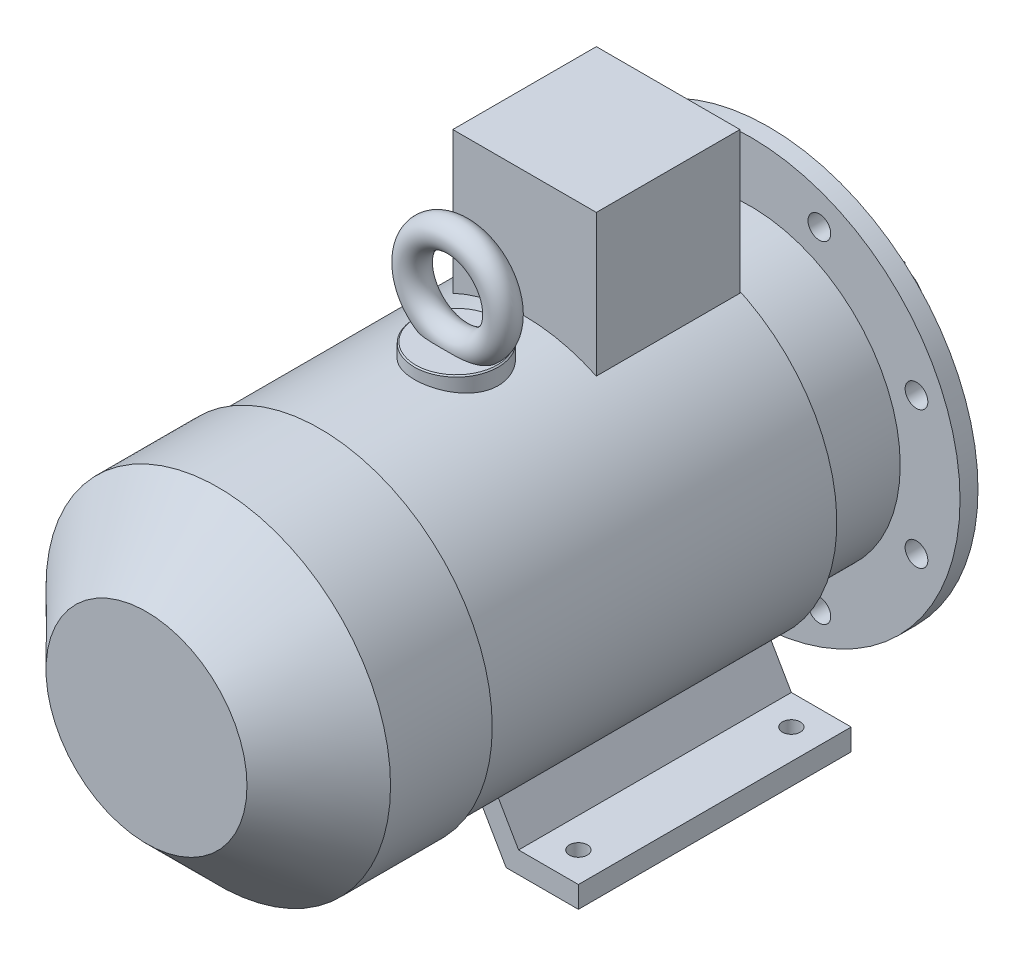
from build123d import *

# Parameters (mm, degrees)
SKETCH_1_R           = 21
EXTRUDE_1_DEPTH      = 110
SKETCH_2_W           = 8
SKETCH_2_H           = 8
EXTRUDE_2_DEPTH      = 0.1
EXTRUDE_2_DEPTH_BACK = 55
SKETCH_3_R           = 175
EXTRUDE_3_DEPTH      = 15
SKETCH_4_R           = 125
SKETCH_4_R_2         = 116
EXTRUDE_4_DEPTH      = 5
SKETCH_5_R           = 116
SKETCH_5_R_2         = 40
CUT_EXTRUDE_1_DEPTH  = 8
CHAMFER_1_SIZE       = 1
SKETCH_6_R           = 9.5
CUT_EXTRUDE_2_DEPTH  = 16
SKETCH_7_R           = 125
EXTRUDE_5_DEPTH      = 68
SKETCH_8_R           = 140
EXTRUDE_6_DEPTH      = 292
SKETCH_9_R           = 144
EXTRUDE_7_DEPTH      = 145
CHAMFER_2_SIZE       = 60
EXTRUDE_8_DEPTH      = 228
CUT_EXTRUDE_3_REACH  = 337
SKETCH_11_R          = 7.5
SKETCH_12_W          = 120
SKETCH_12_H          = 120
EXTRUDE_9_DEPTH      = 245
SKETCH_13_R          = 35
EXTRUDE_10_DEPTH     = 150
CHAMFER_3_SIZE       = 1
SKETCH_15_R          = 12
SKETCH_16_R          = 16
EXTRUDE_11_DEPTH     = 14
EXTRUDE_12_DEPTH     = 16
SKETCH_18_R          = 7
CUT_EXTRUDE_4_DEPTH  = 16


with BuildPart() as part:
    # Эскиз1 → Вытянуть1 (new body)
    with BuildSketch(Plane.XY):
        Circle(SKETCH_1_R)
    extrude(amount=EXTRUDE_1_DEPTH)

    # Эскиз2 → Вытянуть2 (add, two sides)
    with BuildSketch(Plane(origin=(0, 0, 0), x_dir=(-1, 0, 0), z_dir=(0, 0, -1))) as extrude_2_sk:
        with Locations((0, 20)):
            Rectangle(SKETCH_2_W, SKETCH_2_H)
    extrude(amount=EXTRUDE_2_DEPTH)
    extrude(extrude_2_sk.sketch, amount=-EXTRUDE_2_DEPTH_BACK)

    # Эскиз3 → Вытянуть3 (add)
    with BuildSketch(Plane.XY.offset(110)):
        Circle(SKETCH_3_R)
    extrude(amount=EXTRUDE_3_DEPTH)

    # Эскиз4 → Вытянуть4 (add)
    with BuildSketch(Plane(origin=(0, 0, 110), x_dir=(-1, 0, 0), z_dir=(0, 0, -1))):
        with Locations(Location((0, 0, 0), (0, 0, 180))):  # turned: the seam where the file's is
            Circle(SKETCH_4_R)
        Circle(SKETCH_4_R_2, mode=Mode.SUBTRACT)
    extrude(amount=EXTRUDE_4_DEPTH)

    # Эскиз5 → Вырез-Вытянуть1 (cut)
    with BuildSketch(Plane(origin=(0, 0, 110), x_dir=(-1, 0, 0), z_dir=(0, 0, -1))):
        Circle(SKETCH_5_R)
        Circle(SKETCH_5_R_2, mode=Mode.SUBTRACT)
    extrude(amount=-CUT_EXTRUDE_1_DEPTH, mode=Mode.SUBTRACT)

    # Фаска1
    chamfer_1_edges = [part.edges().sort_by_distance(p)[0] for p in [
        (-125, 0, 105),
        (40, 0, 110),
        (-13.360389216, -16.201851746, 0),
    ]]
    chamfer(chamfer_1_edges, length=CHAMFER_1_SIZE)

    # Эскиз6 → Вырез-Вытянуть2 (cut, through all)
    with BuildSketch(Plane(origin=(0, 0, 110), x_dir=(-1, 0, 0), z_dir=(0, 0, -1))):
        with Locations((-57.402514855, 138.581929877)):
            Circle(SKETCH_6_R)
        with Locations((57.402514855, 138.581929877)):
            Circle(SKETCH_6_R)
        with Locations((138.581929877, 57.402514855)):
            Circle(SKETCH_6_R)
        with Locations((138.581929877, -57.402514855)):
            Circle(SKETCH_6_R)
        with Locations((57.402514855, -138.581929877)):
            Circle(SKETCH_6_R)
        with Locations((-57.402514855, -138.581929877)):
            Circle(SKETCH_6_R)
        with Locations((-138.581929877, -57.402514855)):
            Circle(SKETCH_6_R)
        with Locations((-138.581929877, 57.402514855)):
            Circle(SKETCH_6_R)
    extrude(amount=-CUT_EXTRUDE_2_DEPTH, mode=Mode.SUBTRACT)

    # Эскиз7 → Вытянуть5 (add)
    with BuildSketch(Plane.XY.offset(125)):
        Circle(SKETCH_7_R)
    extrude(amount=EXTRUDE_5_DEPTH)

    # Эскиз8 → Вытянуть6 (add)
    with BuildSketch(Plane.XY.offset(193)):
        Circle(SKETCH_8_R)
    extrude(amount=EXTRUDE_6_DEPTH)

    # Эскиз9 → Вытянуть7 (add)
    with BuildSketch(Plane.XY.offset(485)):
        Circle(SKETCH_9_R)
    extrude(amount=EXTRUDE_7_DEPTH)

    # Фаска2
    chamfer_2_edges = [part.edges().sort_by_distance(p)[0] for p in [
        (-144, 0, 630),
    ]]
    chamfer(chamfer_2_edges, length=CHAMFER_2_SIZE)

    # Эскиз10 → Вытянуть8 (add)
    with BuildSketch(Plane(origin=(0, 0, 193), x_dir=(-1, 0, 0), z_dir=(0, 0, -1))):
        Polygon((-152, -160), (-91.607695155, -160), (-51.945448858, -91.302974272), (-67.533906126, -82.302974272), (-102, -142), (-152, -142), align=None)
        Polygon((91.607695155, -160), (51.945448858, -91.302974272), (67.533906126, -82.302974272), (102, -142), (152, -142), (152, -160), align=None)
    extrude(amount=-EXTRUDE_8_DEPTH)

    # Эскиз11 → Вырез-Вытянуть3 (cut, up to next)
    with BuildSketch(Plane.XZ.offset(160), mode=Mode.PRIVATE) as cut_extrude_3_sk1:
        with Locations((-127, 218)):
            Circle(SKETCH_11_R)
    cut_extrude_3_tool1 = extrude(cut_extrude_3_sk1.sketch, amount=-CUT_EXTRUDE_3_REACH, mode=Mode.PRIVATE) & part.part
    add(cut_extrude_3_tool1.solids().sort_by_distance((-127, -160, 218))[0], mode=Mode.SUBTRACT)
    # Эскиз11 → Вырез-Вытянуть3 (cut, up to next)
    with BuildSketch(Plane.XZ.offset(160), mode=Mode.PRIVATE) as cut_extrude_3_sk2:
        with Locations((127, 218)):
            Circle(SKETCH_11_R)
    cut_extrude_3_tool2 = extrude(cut_extrude_3_sk2.sketch, amount=-CUT_EXTRUDE_3_REACH, mode=Mode.PRIVATE) & part.part
    add(cut_extrude_3_tool2.solids().sort_by_distance((127, -160, 218))[0], mode=Mode.SUBTRACT)
    # Эскиз11 → Вырез-Вытянуть3 (cut, up to next)
    with BuildSketch(Plane.XZ.offset(160), mode=Mode.PRIVATE) as cut_extrude_3_sk3:
        with Locations((-127, 396)):
            Circle(SKETCH_11_R)
    cut_extrude_3_tool3 = extrude(cut_extrude_3_sk3.sketch, amount=-CUT_EXTRUDE_3_REACH, mode=Mode.PRIVATE) & part.part
    add(cut_extrude_3_tool3.solids().sort_by_distance((-127, -160, 396))[0], mode=Mode.SUBTRACT)
    # Эскиз11 → Вырез-Вытянуть3 (cut, up to next)
    with BuildSketch(Plane.XZ.offset(160), mode=Mode.PRIVATE) as cut_extrude_3_sk4:
        with Locations((127, 396)):
            Circle(SKETCH_11_R)
    cut_extrude_3_tool4 = extrude(cut_extrude_3_sk4.sketch, amount=-CUT_EXTRUDE_3_REACH, mode=Mode.PRIVATE) & part.part
    add(cut_extrude_3_tool4.solids().sort_by_distance((127, -160, 396))[0], mode=Mode.SUBTRACT)

    # Эскиз12 → Вытянуть9 (add)
    with BuildSketch(Plane(origin=(0, 0, 0), x_dir=(1, 0, 0), z_dir=(0, 1, 0))):
        with Locations((0, -254)):
            Rectangle(SKETCH_12_W, SKETCH_12_H)
    extrude(amount=EXTRUDE_9_DEPTH)

    # Эскиз13 → Вытянуть10 (add)
    with BuildSketch(Plane(origin=(0, 0, 0), x_dir=(1, 0, 0), z_dir=(0, 1, 0))):
        with Locations(Location((0, -371, 0), (0, 0, 90))):  # turned: the seam where the file's is
            Circle(SKETCH_13_R)
    extrude(amount=EXTRUDE_10_DEPTH)

    # Фаска3
    chamfer_3_edges = [part.edges().sort_by_distance(p)[0] for p in [
        (0, 150, 406),
    ]]
    chamfer(chamfer_3_edges, length=CHAMFER_3_SIZE)

    # По траектории1: sweep along a path in Эскиз14
    with BuildLine(Plane.XY.offset(370)) as sweep_1_path:
        CenterArc((0, 188), 38, 0, 360)
    # Эскиз15 → По траектории1 (sweep)
    with BuildSketch(Plane(origin=(0, 0, 0), x_dir=(0, 0, -1), z_dir=(1, 0, 0))):
        with Locations((-370, 226)):
            Circle(SKETCH_15_R)
    sweep(path=sweep_1_path.line)

    # Эскиз16 → Вытянуть11 (add)
    with BuildSketch(Plane.ZY.offset(60)):
        with Locations(Location((254, 185, 0), (0, 0, 180))):  # turned: the seam where the file's is
            Circle(SKETCH_16_R)
    extrude(amount=EXTRUDE_11_DEPTH)

    # Эскиз17 → Вытянуть12 (add)
    with BuildSketch(Plane.ZY.offset(74)):
        Polygon((254, 207.516660498), (234.5, 196.258330249), (234.5, 173.741669751), (254, 162.483339502), (273.5, 173.741669751), (273.5, 196.258330249), align=None)
    extrude(amount=EXTRUDE_12_DEPTH)

    # Эскиз18 → Вырез-Вытянуть4 (cut)
    with BuildSketch(Plane.ZY.offset(90)):
        with Locations((254, 185)):
            Circle(SKETCH_18_R)
    extrude(amount=-CUT_EXTRUDE_4_DEPTH, mode=Mode.SUBTRACT)


solid = part.part
